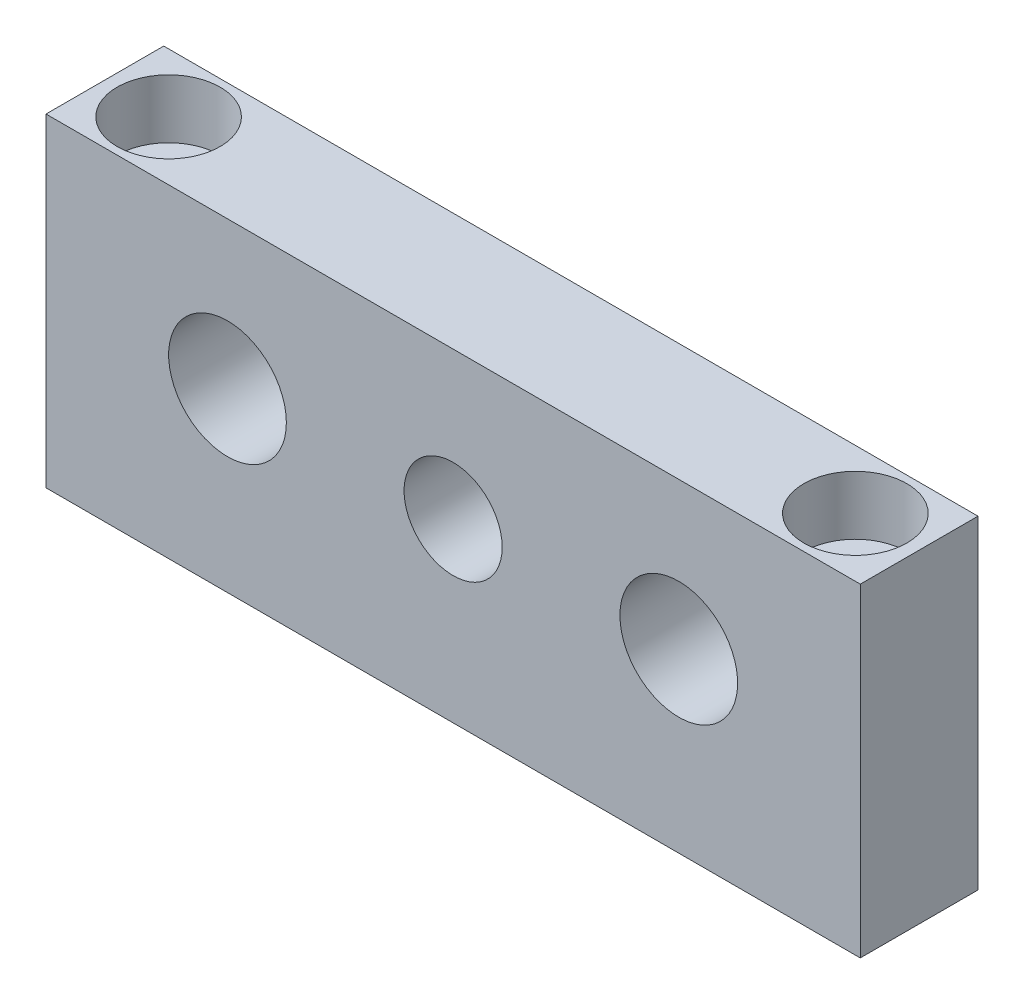
from build123d import *

# Parameters (mm, degrees)
SKETCH1_W           = 83
SKETCH1_H           = 33
BOSS_EXTRUDE1_DEPTH = 12
SKETCH2_R           = 5
SKETCH2_R_2         = 6
CUT_EXTRUDE1_DEPTH  = 13
SKETCH3_R           = 3
CUT_EXTRUDE2_DEPTH  = 34
SKETCH4_R           = 5.25
CUT_EXTRUDE3_DEPTH  = 6


with BuildPart() as part:
    # Sketch1 → Boss-Extrude1 (new body)
    with BuildSketch(Plane.XY):
        Rectangle(SKETCH1_W, SKETCH1_H)
    extrude(amount=BOSS_EXTRUDE1_DEPTH)

    # Sketch2 → Cut-Extrude1 (cut, through all)
    with BuildSketch(Plane.XY.offset(12)):
        with Locations((0, 1.5)):
            Circle(SKETCH2_R)
        with Locations((-23, 1.5)):
            Circle(SKETCH2_R_2)
        with Locations((23, 1.5)):
            Circle(SKETCH2_R_2)
    extrude(amount=-CUT_EXTRUDE1_DEPTH, mode=Mode.SUBTRACT)

    # Sketch3 → Cut-Extrude2 (cut, through all)
    with BuildSketch(Plane(origin=(0, 16.5, 0), x_dir=(1, 0, 0), z_dir=(0, 1, 0))):
        with Locations((-35, -6)):
            Circle(SKETCH3_R)
        with Locations((35, -6)):
            Circle(SKETCH3_R)
    extrude(amount=-CUT_EXTRUDE2_DEPTH, mode=Mode.SUBTRACT)

    # Sketch4 → Cut-Extrude3 (cut)
    with BuildSketch(Plane(origin=(0, 16.5, 0), x_dir=(1, 0, 0), z_dir=(0, 1, 0))):
        with Locations((-35, -6)):
            Circle(SKETCH4_R)
        with Locations((35, -6)):
            Circle(SKETCH4_R)
    extrude(amount=-CUT_EXTRUDE3_DEPTH, mode=Mode.SUBTRACT)


solid = part.part
